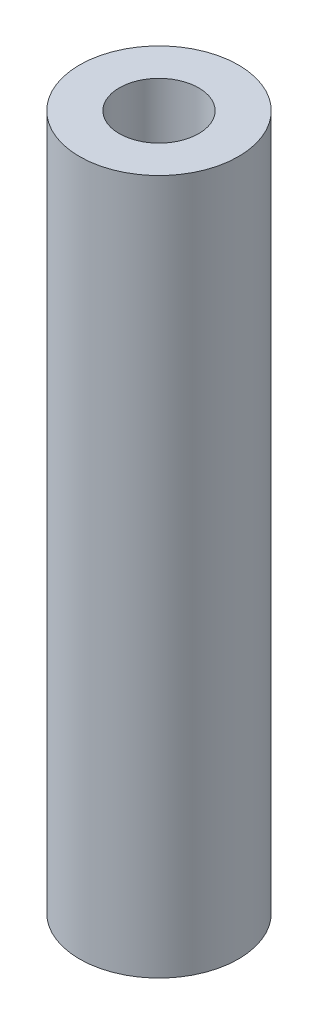
from build123d import *

# Parameters (mm, degrees)
CROQUIS1_R              = 4
SALIENTE_EXTRUIR1_DEPTH = 35
CROQUIS2_R              = 2
CORTAR_EXTRUIR1_DEPTH   = 5


with BuildPart() as part:
    # Croquis1 → Saliente-Extruir1 (new body)
    with BuildSketch(Plane(origin=(0, 0, 0), x_dir=(1, 0, 0), z_dir=(0, 1, 0))):
        Circle(CROQUIS1_R)
    extrude(amount=SALIENTE_EXTRUIR1_DEPTH)

    # Croquis2 → Cortar-Extruir1 (cut)
    with BuildSketch(Plane(origin=(0, 35, 0), x_dir=(1, 0, 0), z_dir=(0, 1, 0))):
        Circle(CROQUIS2_R)
    extrude(amount=-CORTAR_EXTRUIR1_DEPTH, mode=Mode.SUBTRACT)


solid = part.part
